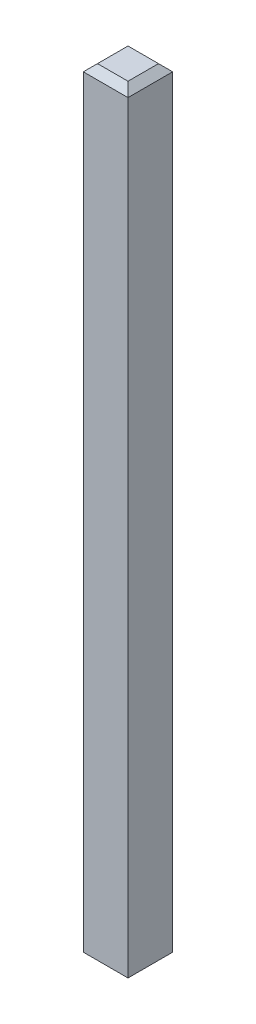
from build123d import *

# Parameters (mm, degrees)
SKETCH1_W           = 0.63
SKETCH1_H           = 0.63
BOSS_EXTRUDE1_DEPTH = 10.95
CHAMFER1_SIZE       = 0.1


with BuildPart() as part:
    # Sketch1 → Boss-Extrude1 (new body)
    with BuildSketch(Plane(origin=(0, 0, 0), x_dir=(1, 0, 0), z_dir=(0, 1, 0))):
        Rectangle(SKETCH1_W, SKETCH1_H)
    extrude(amount=BOSS_EXTRUDE1_DEPTH)

    # Chamfer1
    chamfer1_edges = [part.edges().sort_by_distance(p)[0] for p in [
        (-0.315, 10.95, 0),
        (0, 10.95, 0.315),
        (0.315, 10.95, 0),
        (0, 0, 0.315),
        (-0.315, 0, 0),
        (0, 0, -0.315),
        (0.315, 0, 0),
        (0, 10.95, -0.315),
    ]]
    chamfer(chamfer1_edges, length=CHAMFER1_SIZE)


solid = part.part
